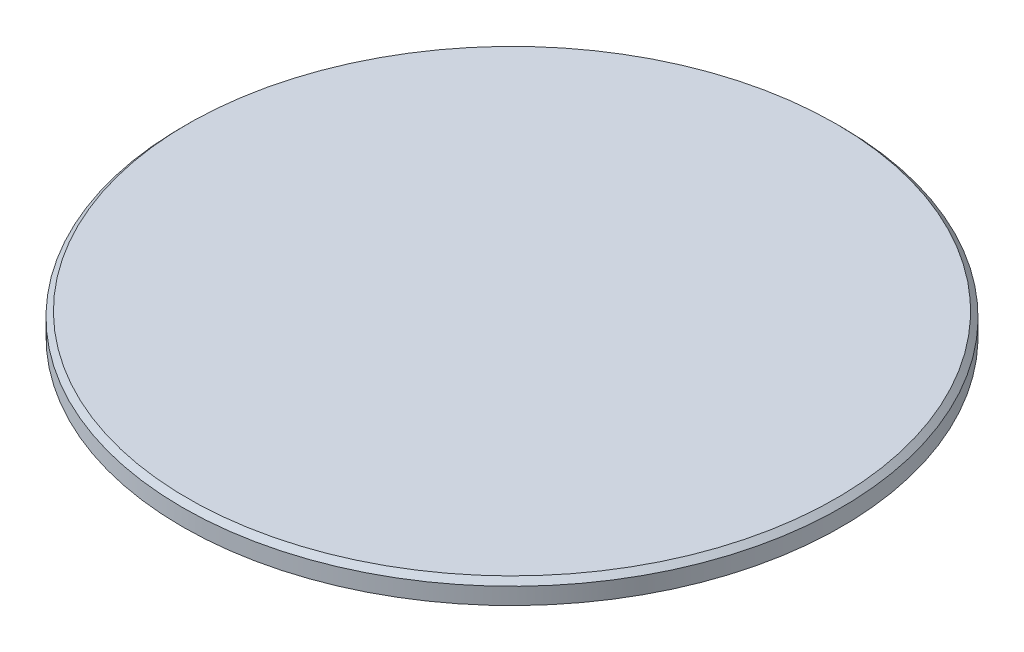
from build123d import *

# Parameters (mm, degrees)
SKETCH_4_R               = 4
CUT_EXTRUDE_1_DEPTH      = 2
PATTERN_CIRCULAR_1_COUNT = 6
CHAMFER_1_SIZE           = 0.6


with BuildPart() as part:
    # Эскиз1 → Повернуть1 (revolve)
    with BuildSketch(Plane.XY):
        Polygon((0, 0), (-37.5, 0), (-37.5, -2.5), (-24.65, -2.5), (-24.65, -5.5), (-20, -5.5), (-20, -2.5), (0, -2.5), align=None)
    revolve(axis=Axis((0, 0, 0), (0, 1, 0)))

    # Эскиз4 → Cut-Extrude 1 (cut)
    with BuildSketch(Plane.XZ.offset(2.5)):
        with Locations((-31, 0)):
            Circle(SKETCH_4_R)
    cut_extrude_1 = extrude(amount=-CUT_EXTRUDE_1_DEPTH, mode=Mode.SUBTRACT)

    # Круговой массив1: Cut-Extrude 1 ×6 about axis
    pattern_circular_1_axis = Axis((0, 0, 0), (0, 1, 0))
    for i in range(1, PATTERN_CIRCULAR_1_COUNT):
        add(cut_extrude_1.rotate(pattern_circular_1_axis, i * 360 / PATTERN_CIRCULAR_1_COUNT), mode=Mode.SUBTRACT)

    # Фаска1
    chamfer_1_edges = [part.edges().sort_by_distance(p)[0] for p in [
        (24.65, -5.5, 0),
        (37.5, 0, 0),
    ]]
    chamfer(chamfer_1_edges, length=CHAMFER_1_SIZE)


solid = part.part
